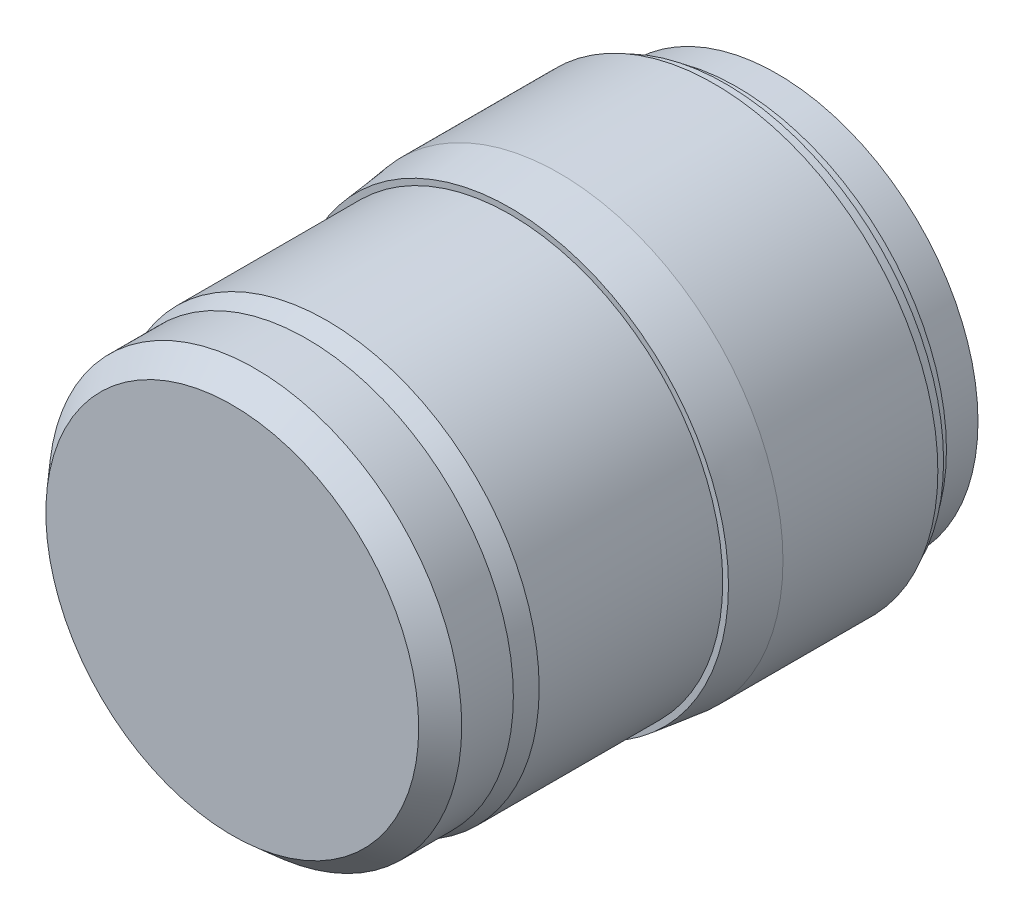
from build123d import *


with BuildPart() as part:
    # Эскиз1 → Повернуть1 (revolve)
    with BuildSketch(Plane(origin=(0, 0, 0), x_dir=(1, 0, 0), z_dir=(0, 1, 0))):
        Polygon((0, 95), (35, 95), (35, 88), (36.5, 88), (36.5, 86.000977097), (38, 86.000977097), (38, 84.000977097), (39, 84.000977097), (39, 57.000977097), (38, 48.500977097), (37, 48.500977097), (37, 16.500977097), (36, 13), (36, 4), (32.5, 0), (0, 0), align=None)
    revolve(axis=Axis((0, 0, 0), (0, 0, -1)))


solid = part.part
